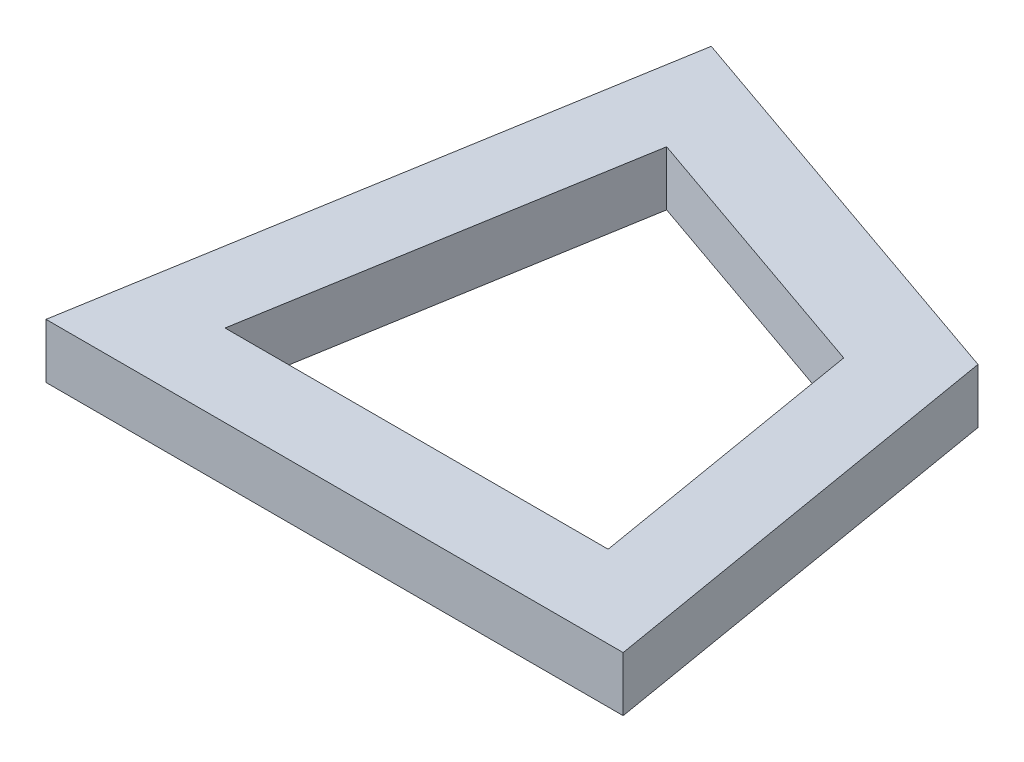
from build123d import *

# Parameters (mm, degrees)
BOSS_EXTRUDE1_DEPTH = 2


with BuildPart() as part:
    # Sketch1 → Boss-Extrude1 (new body)
    with BuildSketch(Plane(origin=(0, 0, 0), x_dir=(1, 0, 0), z_dir=(0, 1, 0))):
        Polygon((0, 0), (21.11421446, 0), (18.47519345, 15.619407395), (3.517557511, 20.81914603), align=None)
        Polygon((5.884430734, 16.82024507), (3.549392266, 3), (17.564822194, 3), (15.812934214, 13.368789015), align=None, mode=Mode.SUBTRACT)
    extrude(amount=BOSS_EXTRUDE1_DEPTH)


solid = part.part
